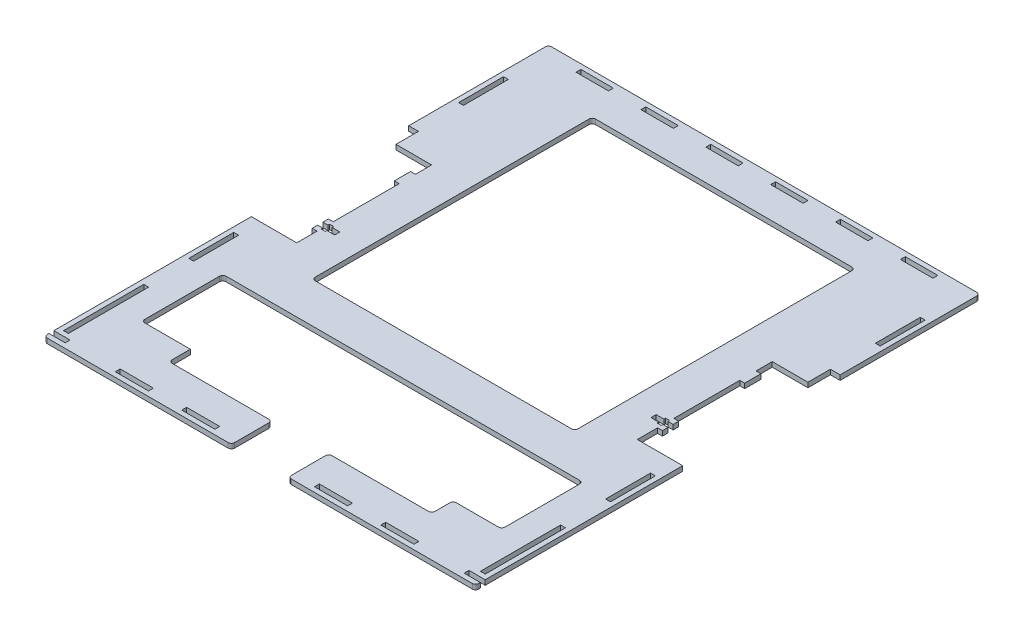
from build123d import *

# Parameters (mm, degrees)
SKETCH1_W               = 3
SKETCH1_H               = 49.4545
SKETCH1_W_2             = 20.4615
SKETCH1_H_2             = 3
SKETCH1_H_3             = 27.7273
SKETCH1_W_3             = 162
SKETCH1_H_4             = 261
SKETCH1_W_4             = 20
BOSS_EXTRUDE1_DEPTH     = 3
SKETCH2_W               = 10.5
SKETCH2_H               = 3.2
SKETCH2_W_2             = 2.5
SKETCH2_H_2             = 5.2
CUT_EXTRUDE1_DEPTH      = 10
SKETCH3_W               = 35
SKETCH3_H               = 25
SKETCH3_W_2             = 30
SKETCH3_H_2             = 50
CUT_EXTRUDE2_DEPTH      = 1
CUT_EXTRUDE2_DEPTH_BACK = 4
SKETCH4_W               = 162
SKETCH4_H               = 25
BOSS_EXTRUDE2_DEPTH     = 3
FILLET1_R               = 2


with BuildPart() as part:
    # Sketch1 → Boss-Extrude1 (new body)
    with BuildSketch(Plane(origin=(0, 0, 0), x_dir=(1, 0, 0), z_dir=(0, 1, 0))):
        Polygon((-133, -152.5), (-133, -155.5), (133, -155.5), (133, -152.5), (123, -152.5), (123, -149.5), (133, -149.5), (133, -27.7273), (105, -27.7273), (105, -15.2273), (108, -15.2273), (108, -5.2273), (105, -5.2273), (105, 35.4545), (108, 35.4545), (108, 45.4545), (105, 45.4545), (105, 55.4545), (127, 55.4545), (127, 69.3181), (133, 69.3181), (133, 155.5), (-133, 155.5), (-133, 69.3181), (-127, 69.3181), (-127, 55.4545), (-105, 55.4545), (-105, 45.4545), (-108, 45.4545), (-108, 35.4545), (-105, 35.4545), (-105, -5.2273), (-108, -5.2273), (-108, -15.2273), (-105, -15.2273), (-105, -27.7273), (-133, -27.7273), (-133, -149.5), (-123, -149.5), (-123, -152.5), align=None)
        with Locations((-128.5, -121.77275)):
            Rectangle(SKETCH1_W, SKETCH1_H, mode=Mode.SUBTRACT)
        with Locations((-81.846, -151)):
            Rectangle(SKETCH1_W_2, SKETCH1_H_2, mode=Mode.SUBTRACT)
        with Locations((-40.923, -151)):
            Rectangle(SKETCH1_W_2, SKETCH1_H_2, mode=Mode.SUBTRACT)
        with Locations((0, -151)):
            Rectangle(SKETCH1_W_2, SKETCH1_H_2, mode=Mode.SUBTRACT)
        with Locations((-128.5, -55.45455)):
            Rectangle(SKETCH1_W, SKETCH1_H_3, mode=Mode.SUBTRACT)
        with Locations((40.923, -151)):
            Rectangle(SKETCH1_W_2, SKETCH1_H_2, mode=Mode.SUBTRACT)
        with Locations((81.846, -151)):
            Rectangle(SKETCH1_W_2, SKETCH1_H_2, mode=Mode.SUBTRACT)
        with Locations((128.5, -121.77275)):
            Rectangle(SKETCH1_W, SKETCH1_H, mode=Mode.SUBTRACT)
        with Locations((128.5, -55.45455)):
            Rectangle(SKETCH1_W, SKETCH1_H_3, mode=Mode.SUBTRACT)
        Rectangle(SKETCH1_W_3, SKETCH1_H_4, mode=Mode.SUBTRACT)
        with Locations((-128.5, 110.90905)):
            Rectangle(SKETCH1_W, SKETCH1_H_3, mode=Mode.SUBTRACT)
        with Locations((-100, 151)):
            Rectangle(SKETCH1_W_4, SKETCH1_H_2, mode=Mode.SUBTRACT)
        with Locations((-60, 151)):
            Rectangle(SKETCH1_W_4, SKETCH1_H_2, mode=Mode.SUBTRACT)
        with Locations((-20, 151)):
            Rectangle(SKETCH1_W_4, SKETCH1_H_2, mode=Mode.SUBTRACT)
        with Locations((20, 151)):
            Rectangle(SKETCH1_W_4, SKETCH1_H_2, mode=Mode.SUBTRACT)
        with Locations((60, 151)):
            Rectangle(SKETCH1_W_4, SKETCH1_H_2, mode=Mode.SUBTRACT)
        with Locations((128.5, 110.90905)):
            Rectangle(SKETCH1_W, SKETCH1_H_3, mode=Mode.SUBTRACT)
        with Locations((100, 151)):
            Rectangle(SKETCH1_W_4, SKETCH1_H_2, mode=Mode.SUBTRACT)
    extrude(amount=BOSS_EXTRUDE1_DEPTH)

    # Sketch2 → Cut-Extrude1 (cut)
    with BuildSketch(Plane(origin=(0, 3, 0), x_dir=(1, 0, 0), z_dir=(0, 1, 0))):
        with Locations((-102.75, -10.2273)):
            Rectangle(SKETCH2_W, SKETCH2_H)
        with Locations((102.75, -10.2273)):
            Rectangle(SKETCH2_W, SKETCH2_H)
        with Locations((103.575, -10.2273)):
            Rectangle(SKETCH2_W_2, SKETCH2_H_2)
        with Locations((-103.575, -10.2273)):
            Rectangle(SKETCH2_W_2, SKETCH2_H_2)
    extrude(amount=-CUT_EXTRUDE1_DEPTH, mode=Mode.SUBTRACT)

    # Sketch3 → Cut-Extrude2 (cut, two sides)
    with BuildSketch(Plane(origin=(0, 3, 0), x_dir=(1, 0, 0), z_dir=(0, 1, 0))) as cut_extrude2_sk:
        with Locations((0, -143)):
            Rectangle(SKETCH3_W, SKETCH3_H)
        with Locations((-96, -92.3182)):
            Rectangle(SKETCH3_W_2, SKETCH3_H_2)
        with Locations((96, -92.3182)):
            Rectangle(SKETCH3_W_2, SKETCH3_H_2)
    extrude(amount=CUT_EXTRUDE2_DEPTH, mode=Mode.SUBTRACT)
    extrude(cut_extrude2_sk.sketch, amount=-CUT_EXTRUDE2_DEPTH_BACK, mode=Mode.SUBTRACT)

    # Sketch4 → Boss-Extrude2 (add)
    with BuildSketch(Plane.XZ):
        with Locations((0, 54.8182)):
            Rectangle(SKETCH4_W, SKETCH4_H)
    extrude(amount=-BOSS_EXTRUDE2_DEPTH)

    # Fillet1
    fillet1_edges = [part.edges().sort_by_distance(p)[0] for p in [
        (-133, 1.5, -155.5),
        (133, 1.5, -155.5),
        (133, 1.5, 155.5),
        (-133, 1.5, 155.5),
        (81, 1.5, -130.5),
        (-81, 1.5, -130.5),
        (-81, 1.5, 130.5),
        (81, 1.5, 130.5),
        (17.5, 1.5, 130.5),
        (17.5, 1.5, 155.5),
        (-17.5, 1.5, 155.5),
        (-17.5, 1.5, 130.5),
        (-111, 1.5, 117.3182),
        (-111, 1.5, 67.3182),
        (81, 1.5, 117.3182),
        (111, 1.5, 67.3182),
        (111, 1.5, 117.3182),
        (-81, 1.5, 42.3182),
        (81, 1.5, 42.3182),
    ]]
    fillet(fillet1_edges, radius=FILLET1_R)


solid = part.part
